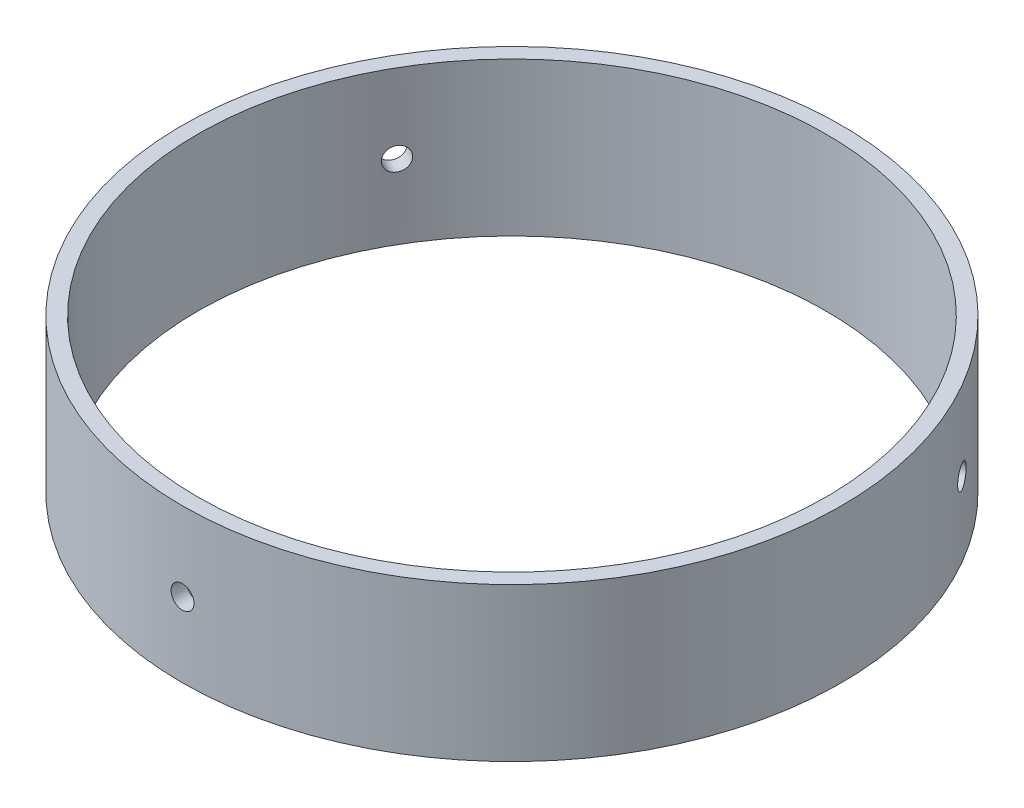
from build123d import *

# Parameters (mm, degrees)
SKETCH1_R           = 54.61
SKETCH1_R_2         = 52.07
BOSS_EXTRUDE1_DEPTH = 25.4
SKETCH3_R           = 1.905
CUT_EXTRUDE1_DEPTH  = 55.61
CIRPATTERN1_COUNT   = 3


with BuildPart() as part:
    # Sketch1 → Boss-Extrude1 (new body)
    with BuildSketch(Plane(origin=(0, 0, 0), x_dir=(1, 0, 0), z_dir=(0, 1, 0))):
        Circle(SKETCH1_R)
        Circle(SKETCH1_R_2, mode=Mode.SUBTRACT)
    extrude(amount=BOSS_EXTRUDE1_DEPTH)

    # Sketch3 → Cut-Extrude1 (cut, through all)
    with BuildSketch(Plane.XY):
        with Locations((0, 12.328955527)):
            Circle(SKETCH3_R)
    cut_extrude1 = extrude(amount=CUT_EXTRUDE1_DEPTH, mode=Mode.SUBTRACT)

    # CirPattern1: Cut-Extrude1 ×3 about axis
    cirpattern1_axis = Axis((0, 25.4, 0), (0, 1, 0))
    for i in range(1, CIRPATTERN1_COUNT):
        add(cut_extrude1.rotate(cirpattern1_axis, i * 360 / CIRPATTERN1_COUNT), mode=Mode.SUBTRACT)


solid = part.part
